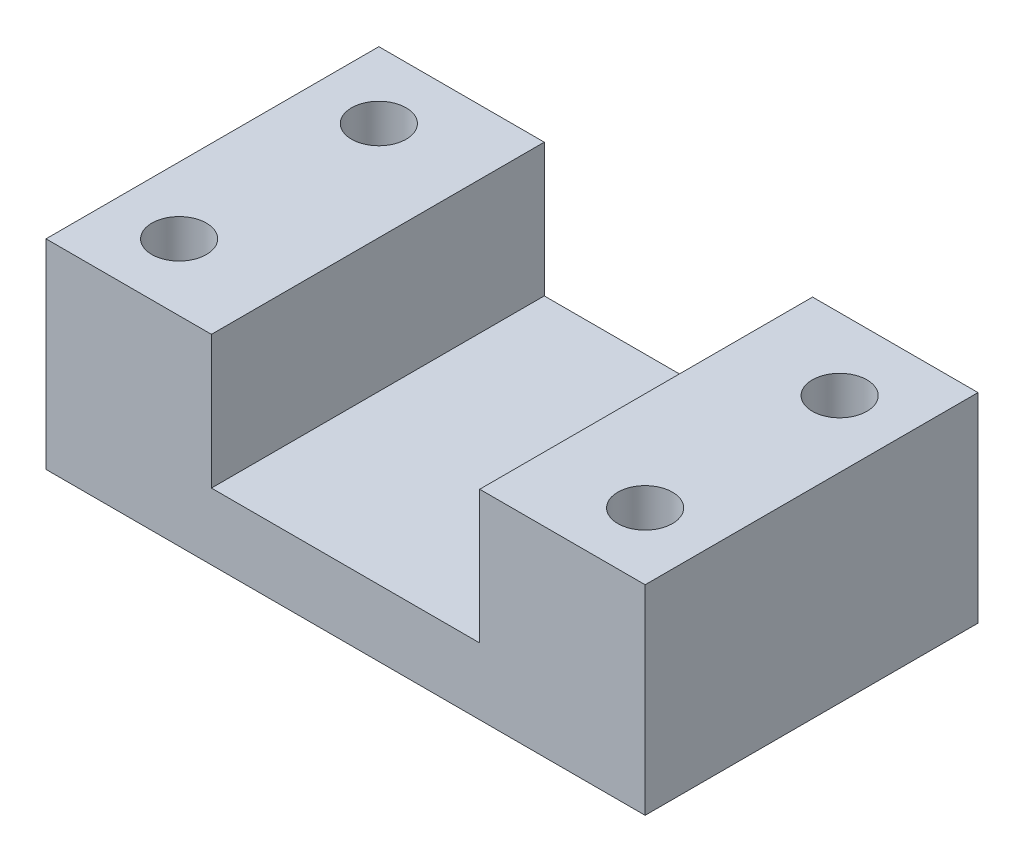
from build123d import *

# Parameters (mm, degrees)
SKETCH1_W           = 90
SKETCH1_H           = 50
BOSS_EXTRUDE1_DEPTH = 30
SKETCH2_W           = 40.3
SKETCH2_H           = 40
CUT_EXTRUDE1_DEPTH  = 51
SKETCH3_R           = 4.1
CUT_EXTRUDE2_DEPTH  = 31
SKETCH4_R           = 8
CUT_EXTRUDE3_DEPTH  = 7


with BuildPart() as part:
    # Sketch1 → Boss-Extrude1 (new body)
    with BuildSketch(Plane(origin=(0, 0, 0), x_dir=(1, 0, 0), z_dir=(0, 1, 0))):
        Rectangle(SKETCH1_W, SKETCH1_H)
    extrude(amount=BOSS_EXTRUDE1_DEPTH)

    # Sketch2 → Cut-Extrude1 (cut, through all)
    with BuildSketch(Plane.XY.offset(25)):
        with Locations((0, 30)):
            Rectangle(SKETCH2_W, SKETCH2_H)
    extrude(amount=-CUT_EXTRUDE1_DEPTH, mode=Mode.SUBTRACT)

    # Sketch3 → Cut-Extrude2 (cut, through all)
    with BuildSketch(Plane.XZ):
        with Locations((-35, 15)):
            Circle(SKETCH3_R)
        with Locations((-35, -15)):
            Circle(SKETCH3_R)
        with Locations((35, -14.217273236)):
            Circle(SKETCH3_R)
        with Locations((35, 15)):
            Circle(SKETCH3_R)
    extrude(amount=-CUT_EXTRUDE2_DEPTH, mode=Mode.SUBTRACT)

    # Sketch4 → Cut-Extrude3 (cut)
    with BuildSketch(Plane.XZ):
        with Locations((35, 15)):
            Circle(SKETCH4_R)
        with Locations((35, -14.217273236)):
            Circle(SKETCH4_R)
        with Locations((-35, 15)):
            Circle(SKETCH4_R)
        with Locations((-35, -15)):
            Circle(SKETCH4_R)
    extrude(amount=-CUT_EXTRUDE3_DEPTH, mode=Mode.SUBTRACT)


solid = part.part
